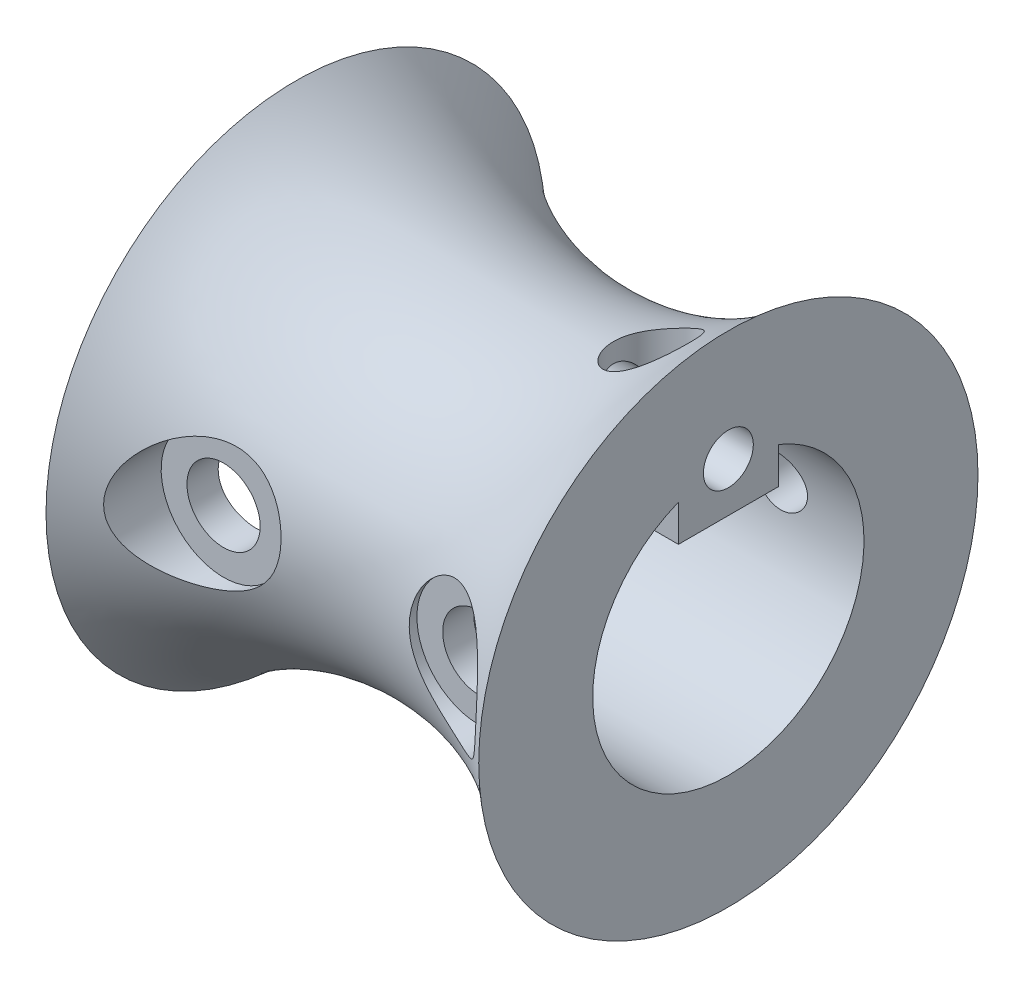
from build123d import *

# Parameters (mm, degrees)
CUT_EXTRUDE1_DEPTH          = 14
SKETCH3_R                   = 0.75
CABLE_HOLE_DEPTH            = 14
SKETCH4_R                   = 1.1303
F_5_40_SET_SCREW_HOLE_DEPTH = 3
SKETCH6_R                   = 0.8
M2_X_0_4_SCREW_HOLE_DEPTH   = 16.0000001
SKETCH7_R                   = 1.1
HOLE_FOR_CAP_SCREW_DEPTH    = 5
SKETCH8_R                   = 1.875
CUT_EXTRUDE6_DEPTH          = 2.5


with BuildPart() as part:
    # Sketch1 → Revolve1 (revolve)
    with BuildSketch(Plane.XY):
        with BuildLine():
            Line((-6.755287009, -0.373111782), (6.244712991, -0.373111782))
            Line((6.244712991, -0.373111782), (6.244712991, 7.126888218))
            ThreePointArc((6.244712991, 7.126888218), (-0.255287009, 4.626888218), (-6.755287009, 7.126888218))
            Line((-6.755287009, 7.126888218), (-6.755287009, -0.373111782))
        make_face()
    revolve(axis=Axis((-6.755287009, -0.373111782, 0), (1, 0, 0)))

    # Sketch2 → Cut-Extrude1 (cut, through all)
    with BuildSketch(Plane.ZY.offset(6.755287009)):
        with BuildLine():
            Line((1.5, 3.315769979), (1.5, 2.315769979))
            Line((1.5, 2.315769979), (-1.5, 2.315769979))
            Line((-1.5, 2.315769979), (-1.5, 3.315769979))
            Line((-1.5, 3.315769979), (-1.5, 3.415769979))
            ThreePointArc((-1.5, 3.415769979), (0, -4.448111782), (1.5, 3.415769979))
            Line((1.5, 3.415769979), (1.5, 3.315769979))
        make_face()
    extrude(amount=-CUT_EXTRUDE1_DEPTH, mode=Mode.SUBTRACT)

    # Sketch3 → cable hole (cut, through all)
    with BuildSketch(Plane(origin=(6.244712991, 0, 0), x_dir=(0, 0, -1), z_dir=(1, 0, 0))):
        with Locations((0, 3.790774627)):
            Circle(SKETCH3_R)
    extrude(amount=-CABLE_HOLE_DEPTH, mode=Mode.SUBTRACT)

    # Sketch4 → 5-40 set screw hole (cut)
    with BuildSketch(Plane(origin=(0, 7.126888218, 0), x_dir=(1, 0, 0), z_dir=(0, 1, 0))):
        with Locations((3.923493578, 0)):
            Circle(SKETCH4_R)
    extrude(amount=-F_5_40_SET_SCREW_HOLE_DEPTH, mode=Mode.SUBTRACT)

    # Sketch6 → M2 X 0.4 screw hole (cut, through all)
    with BuildSketch(Plane.XY.offset(7.5)):
        with Locations((3.762702125, 0)):
            Circle(SKETCH6_R)
        with Locations((-3.920823754, 0)):
            Circle(SKETCH6_R)
    extrude(amount=-M2_X_0_4_SCREW_HOLE_DEPTH, mode=Mode.SUBTRACT)

    # Sketch7 → hole for cap screw (cut)
    with BuildSketch(Plane.XY.offset(7.5)):
        with Locations((3.762702125, 0)):
            Circle(SKETCH7_R)
        with Locations((-3.920823754, 0)):
            Circle(SKETCH7_R)
    extrude(amount=-HOLE_FOR_CAP_SCREW_DEPTH, mode=Mode.SUBTRACT)

    # Sketch8 → Cut-Extrude6 (cut)
    with BuildSketch(Plane.XY.offset(7.5)):
        with Locations((3.762702125, 0)):
            Circle(SKETCH8_R)
        with Locations((-3.920823754, 0)):
            Circle(SKETCH8_R)
    extrude(amount=-CUT_EXTRUDE6_DEPTH, mode=Mode.SUBTRACT)


solid = part.part
